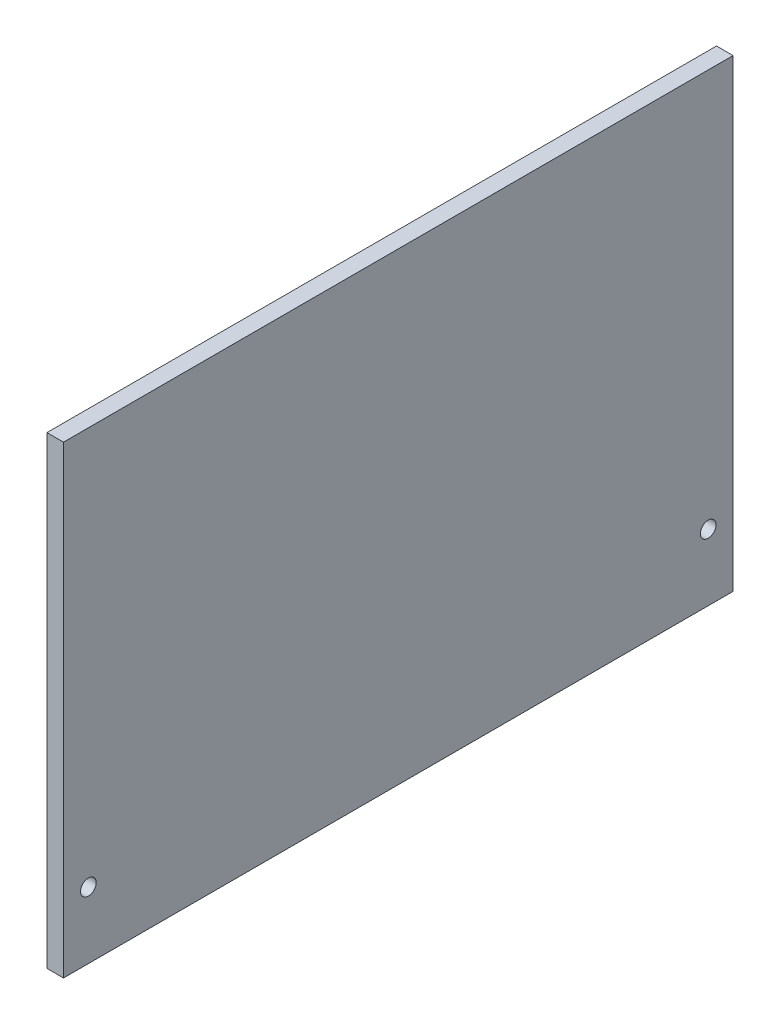
from build123d import *

# Parameters (mm, degrees)
SKETCH1_W           = 128.27
SKETCH1_H           = 88.9
SKETCH1_R           = 1.5
BOSS_EXTRUDE1_DEPTH = 3.175


with BuildPart() as part:
    # Sketch1 → Boss-Extrude1 (new body)
    with BuildSketch(Plane(origin=(0, 0, 0), x_dir=(0, 0, -1), z_dir=(1, 0, 0))):
        Rectangle(SKETCH1_W, SKETCH1_H)
        with Locations((-59.3725, -31.75)):
            Circle(SKETCH1_R, mode=Mode.SUBTRACT)
        with Locations((59.3725, -31.75)):
            Circle(SKETCH1_R, mode=Mode.SUBTRACT)
    extrude(amount=BOSS_EXTRUDE1_DEPTH)


solid = part.part
